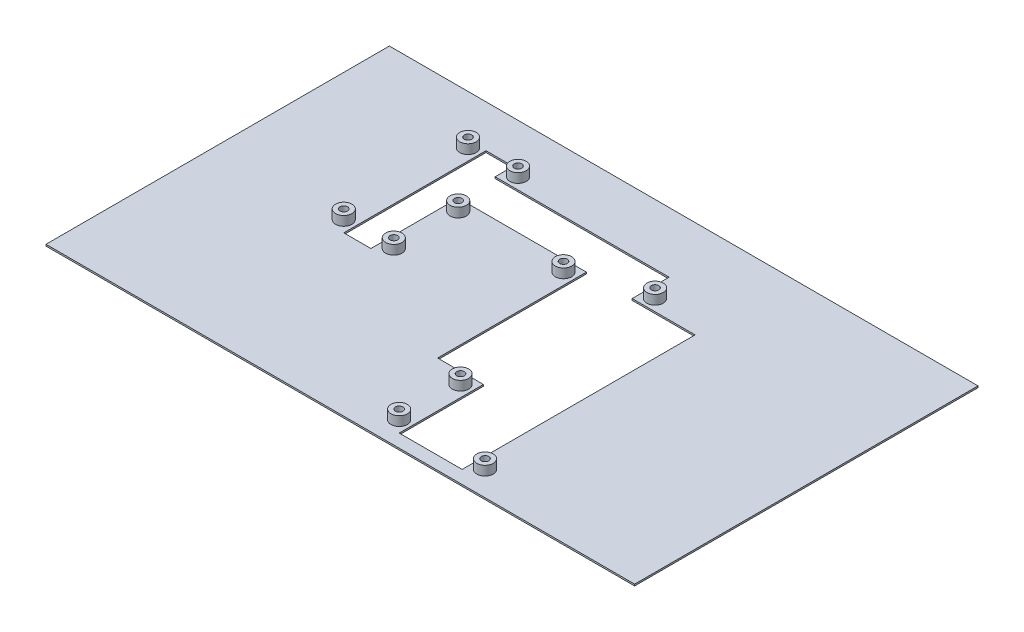
from build123d import *

# Parameters (mm, degrees)
SKETCH1_W           = 360
SKETCH1_H           = 210
BOSS_EXTRUDE1_DEPTH = 1
SKETCH2_R           = 5
SKETCH2_R_2         = 2.3
BOSS_EXTRUDE2_DEPTH = 5.7


with BuildPart() as part:
    # Sketch1 → Boss-Extrude1 (new body)
    with BuildSketch(Plane(origin=(0, 0, 0), x_dir=(1, 0, 0), z_dir=(0, 1, 0))):
        Rectangle(SKETCH1_W, SKETCH1_H)
        Polygon((28, -45.5), (0, -45.5), (0, 45.5), (-78.4, 45.5), (-78.4, -7.9), (-95, -7.9), (-95, 79.1), (-78.4, 79.1), (-78.4, 68.1), (28, 68.1), (28, 45.5), (66.5, 45.5), (66.5, -45.5), (66.5, -97), (28, -97), align=None, mode=Mode.SUBTRACT)
    extrude(amount=BOSS_EXTRUDE1_DEPTH)

    # Sketch2 → Boss-Extrude2 (add)
    with BuildSketch(Plane(origin=(0, 1, 0), x_dir=(1, 0, 0), z_dir=(0, 1, 0))):
        with Locations((-71.4, 75.1)):
            Circle(SKETCH2_R)
        with Locations((-71.4, 75.1)):
            Circle(SKETCH2_R_2, mode=Mode.SUBTRACT)
        with Locations((-71.4, 38.5)):
            Circle(SKETCH2_R)
        with Locations((-71.4, 38.5)):
            Circle(SKETCH2_R_2, mode=Mode.SUBTRACT)
        with Locations((-102, 75.1)):
            Circle(SKETCH2_R)
        with Locations((-102, 75.1)):
            Circle(SKETCH2_R_2, mode=Mode.SUBTRACT)
        with Locations((-7, 38.5)):
            Circle(SKETCH2_R)
        with Locations((-7, 38.5)):
            Circle(SKETCH2_R_2, mode=Mode.SUBTRACT)
        with Locations((35, 52.5)):
            Circle(SKETCH2_R)
        with Locations((35, 52.5)):
            Circle(SKETCH2_R_2, mode=Mode.SUBTRACT)
        with Locations((21, -52.5)):
            Circle(SKETCH2_R)
        with Locations((21, -52.5)):
            Circle(SKETCH2_R_2, mode=Mode.SUBTRACT)
        with Locations((-71.4, -0.9)):
            Circle(SKETCH2_R)
        with Locations((-71.4, -0.9)):
            Circle(SKETCH2_R_2, mode=Mode.SUBTRACT)
        with Locations((-102, -0.9)):
            Circle(SKETCH2_R)
        with Locations((-102, -0.9)):
            Circle(SKETCH2_R_2, mode=Mode.SUBTRACT)
        with Locations((73.5, -90)):
            Circle(SKETCH2_R)
        with Locations((73.5, -90)):
            Circle(SKETCH2_R_2, mode=Mode.SUBTRACT)
        with Locations((21, -90)):
            Circle(SKETCH2_R)
        with Locations((21, -90)):
            Circle(SKETCH2_R_2, mode=Mode.SUBTRACT)
    extrude(amount=BOSS_EXTRUDE2_DEPTH)


solid = part.part
